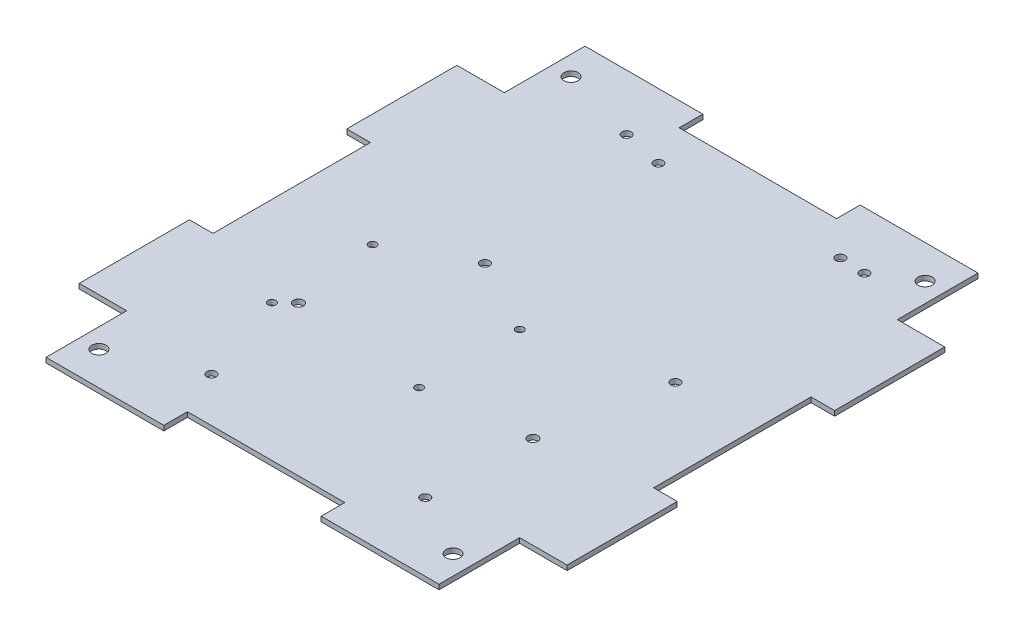
from build123d import *

# Parameters (mm, degrees)
SKETCH1_R          = 2.286
MAIN_BODY_DEPTH    = 1.5875
CUT_EXTRUDE3_REACH = 3.587
SKETCH12_R         = 1.5
SKETCH12_R_2       = 1.25
CUT_EXTRUDE4_REACH = 3.587
SKETCH13_R         = 1.5
SKETCH13_R_2       = 1.625


with BuildPart() as part:
    # Sketch1 → Main Body (new body)
    with BuildSketch(Plane(origin=(0, 0, 0), x_dir=(1, 0, 0), z_dir=(0, 1, 0))):
        Polygon((-25.4, 86.995), (-63.43142, 86.995), (-63.43142, 60.96), (-78.74, 60.96), (-78.74, 25.4), (-71.12, 25.4), (-71.12, -25.4), (-78.74, -25.4), (-78.74, -60.96), (-63.43142, -60.96), (-63.43142, -86.995), (-25.4, -86.995), (-25.4, -79.375), (25.4, -79.375), (25.4, -86.995), (63.43142, -86.995), (63.43142, -60.96), (78.74, -60.96), (78.74, -25.4), (71.12, -25.4), (71.12, 25.4), (78.74, 25.4), (78.74, 60.96), (63.43142, 60.96), (63.43142, 86.995), (25.4, 86.995), (25.4, 79.375), (-25.4, 79.375), align=None)
        with Locations((-57.15, 76.2)):
            Circle(SKETCH1_R, mode=Mode.SUBTRACT)
        with Locations((57.15, 76.2)):
            Circle(SKETCH1_R, mode=Mode.SUBTRACT)
        with Locations((57.15, -76.2)):
            Circle(SKETCH1_R, mode=Mode.SUBTRACT)
        with Locations((-57.15, -76.2)):
            Circle(SKETCH1_R, mode=Mode.SUBTRACT)
    extrude(amount=MAIN_BODY_DEPTH)

    # Sketch12 → Cut-Extrude3 (cut, up to next)
    with BuildSketch(Plane.XZ, mode=Mode.PRIVATE) as cut_extrude3_sk1:
        with Locations((-32, -69)):
            Circle(SKETCH12_R)
    cut_extrude3_tool1 = extrude(cut_extrude3_sk1.sketch, amount=-CUT_EXTRUDE3_REACH, mode=Mode.PRIVATE) & part.part
    add(cut_extrude3_tool1.solids().sort_by_distance((-32, 0, -69))[0], mode=Mode.SUBTRACT)
    # Sketch12 → Cut-Extrude3 (cut, up to next)
    with BuildSketch(Plane.XZ, mode=Mode.PRIVATE) as cut_extrude3_sk2:
        with Locations((37, -69)):
            Circle(SKETCH12_R)
    cut_extrude3_tool2 = extrude(cut_extrude3_sk2.sketch, amount=-CUT_EXTRUDE3_REACH, mode=Mode.PRIVATE) & part.part
    add(cut_extrude3_tool2.solids().sort_by_distance((37, 0, -69))[0], mode=Mode.SUBTRACT)
    # Sketch12 → Cut-Extrude3 (cut, up to next)
    with BuildSketch(Plane.XZ, mode=Mode.PRIVATE) as cut_extrude3_sk3:
        with Locations((37, 65)):
            Circle(SKETCH12_R)
    cut_extrude3_tool3 = extrude(cut_extrude3_sk3.sketch, amount=-CUT_EXTRUDE3_REACH, mode=Mode.PRIVATE) & part.part
    add(cut_extrude3_tool3.solids().sort_by_distance((37, 0, 65))[0], mode=Mode.SUBTRACT)
    # Sketch12 → Cut-Extrude3 (cut, up to next)
    with BuildSketch(Plane.XZ, mode=Mode.PRIVATE) as cut_extrude3_sk4:
        with Locations((-32, 65)):
            Circle(SKETCH12_R)
    cut_extrude3_tool4 = extrude(cut_extrude3_sk4.sketch, amount=-CUT_EXTRUDE3_REACH, mode=Mode.PRIVATE) & part.part
    add(cut_extrude3_tool4.solids().sort_by_distance((-32, 0, 65))[0], mode=Mode.SUBTRACT)
    # Sketch12 → Cut-Extrude3 (cut, up to next)
    with BuildSketch(Plane.XZ, mode=Mode.PRIVATE) as cut_extrude3_sk5:
        with Locations((-42.25, 2.75)):
            Circle(SKETCH12_R_2)
    cut_extrude3_tool5 = extrude(cut_extrude3_sk5.sketch, amount=-CUT_EXTRUDE3_REACH, mode=Mode.PRIVATE) & part.part
    add(cut_extrude3_tool5.solids().sort_by_distance((-42.25, 0, 2.75))[0], mode=Mode.SUBTRACT)
    # Sketch12 → Cut-Extrude3 (cut, up to next)
    with BuildSketch(Plane.XZ, mode=Mode.PRIVATE) as cut_extrude3_sk6:
        with Locations((-42.25, 35.25)):
            Circle(SKETCH12_R_2)
    cut_extrude3_tool6 = extrude(cut_extrude3_sk6.sketch, amount=-CUT_EXTRUDE3_REACH, mode=Mode.PRIVATE) & part.part
    add(cut_extrude3_tool6.solids().sort_by_distance((-42.25, 0, 35.25))[0], mode=Mode.SUBTRACT)
    # Sketch12 → Cut-Extrude3 (cut, up to next)
    with BuildSketch(Plane.XZ, mode=Mode.PRIVATE) as cut_extrude3_sk7:
        with Locations((5.25, 2.75)):
            Circle(SKETCH12_R_2)
    cut_extrude3_tool7 = extrude(cut_extrude3_sk7.sketch, amount=-CUT_EXTRUDE3_REACH, mode=Mode.PRIVATE) & part.part
    add(cut_extrude3_tool7.solids().sort_by_distance((5.25, 0, 2.75))[0], mode=Mode.SUBTRACT)
    # Sketch12 → Cut-Extrude3 (cut, up to next)
    with BuildSketch(Plane.XZ, mode=Mode.PRIVATE) as cut_extrude3_sk8:
        with Locations((5.25, 35.25)):
            Circle(SKETCH12_R_2)
    cut_extrude3_tool8 = extrude(cut_extrude3_sk8.sketch, amount=-CUT_EXTRUDE3_REACH, mode=Mode.PRIVATE) & part.part
    add(cut_extrude3_tool8.solids().sort_by_distance((5.25, 0, 35.25))[0], mode=Mode.SUBTRACT)

    # Sketch13 → Cut-Extrude4 (cut, up to next)
    with BuildSketch(Plane(origin=(0, 1.5875, 0), x_dir=(1, 0, 0), z_dir=(0, 1, 0)), mode=Mode.PRIVATE) as cut_extrude4_sk1:
        with Locations((45.16, 7.6)):
            Circle(SKETCH13_R)
    cut_extrude4_tool1 = extrude(cut_extrude4_sk1.sketch, amount=-CUT_EXTRUDE4_REACH, mode=Mode.PRIVATE) & part.part
    add(cut_extrude4_tool1.solids().sort_by_distance((45.16, 1.5875, -7.6))[0], mode=Mode.SUBTRACT)
    # Sketch13 → Cut-Extrude4 (cut, up to next)
    with BuildSketch(Plane(origin=(0, 1.5875, 0), x_dir=(1, 0, 0), z_dir=(0, 1, 0)), mode=Mode.PRIVATE) as cut_extrude4_sk2:
        with Locations((45.16, 68.6)):
            Circle(SKETCH13_R)
    cut_extrude4_tool2 = extrude(cut_extrude4_sk2.sketch, amount=-CUT_EXTRUDE4_REACH, mode=Mode.PRIVATE) & part.part
    add(cut_extrude4_tool2.solids().sort_by_distance((45.16, 1.5875, -68.6))[0], mode=Mode.SUBTRACT)
    # Sketch13 → Cut-Extrude4 (cut, up to next)
    with BuildSketch(Plane(origin=(0, 1.5875, 0), x_dir=(1, 0, 0), z_dir=(0, 1, 0)), mode=Mode.PRIVATE) as cut_extrude4_sk3:
        with Locations((-18.84, 66.1)):
            Circle(SKETCH13_R)
    cut_extrude4_tool3 = extrude(cut_extrude4_sk3.sketch, amount=-CUT_EXTRUDE4_REACH, mode=Mode.PRIVATE) & part.part
    add(cut_extrude4_tool3.solids().sort_by_distance((-18.84, 1.5875, -66.1))[0], mode=Mode.SUBTRACT)
    # Sketch13 → Cut-Extrude4 (cut, up to next)
    with BuildSketch(Plane(origin=(0, 1.5875, 0), x_dir=(1, 0, 0), z_dir=(0, 1, 0)), mode=Mode.PRIVATE) as cut_extrude4_sk4:
        with Locations((-18.84, 10.1)):
            Circle(SKETCH13_R)
    cut_extrude4_tool4 = extrude(cut_extrude4_sk4.sketch, amount=-CUT_EXTRUDE4_REACH, mode=Mode.PRIVATE) & part.part
    add(cut_extrude4_tool4.solids().sort_by_distance((-18.84, 1.5875, -10.1))[0], mode=Mode.SUBTRACT)
    # Sketch13 → Cut-Extrude4 (cut, up to next)
    with BuildSketch(Plane(origin=(0, 1.5875, 0), x_dir=(1, 0, 0), z_dir=(0, 1, 0)), mode=Mode.PRIVATE) as cut_extrude4_sk5:
        with Locations((-37.85, -31.1)):
            Circle(SKETCH13_R_2)
    cut_extrude4_tool5 = extrude(cut_extrude4_sk5.sketch, amount=-CUT_EXTRUDE4_REACH, mode=Mode.PRIVATE) & part.part
    add(cut_extrude4_tool5.solids().sort_by_distance((-37.85, 1.5875, 31.1))[0], mode=Mode.SUBTRACT)
    # Sketch13 → Cut-Extrude4 (cut, up to next)
    with BuildSketch(Plane(origin=(0, 1.5875, 0), x_dir=(1, 0, 0), z_dir=(0, 1, 0)), mode=Mode.PRIVATE) as cut_extrude4_sk6:
        with Locations((37.85, -31.1)):
            Circle(SKETCH13_R_2)
    cut_extrude4_tool6 = extrude(cut_extrude4_sk6.sketch, amount=-CUT_EXTRUDE4_REACH, mode=Mode.PRIVATE) & part.part
    add(cut_extrude4_tool6.solids().sort_by_distance((37.85, 1.5875, 31.1))[0], mode=Mode.SUBTRACT)


solid = part.part
